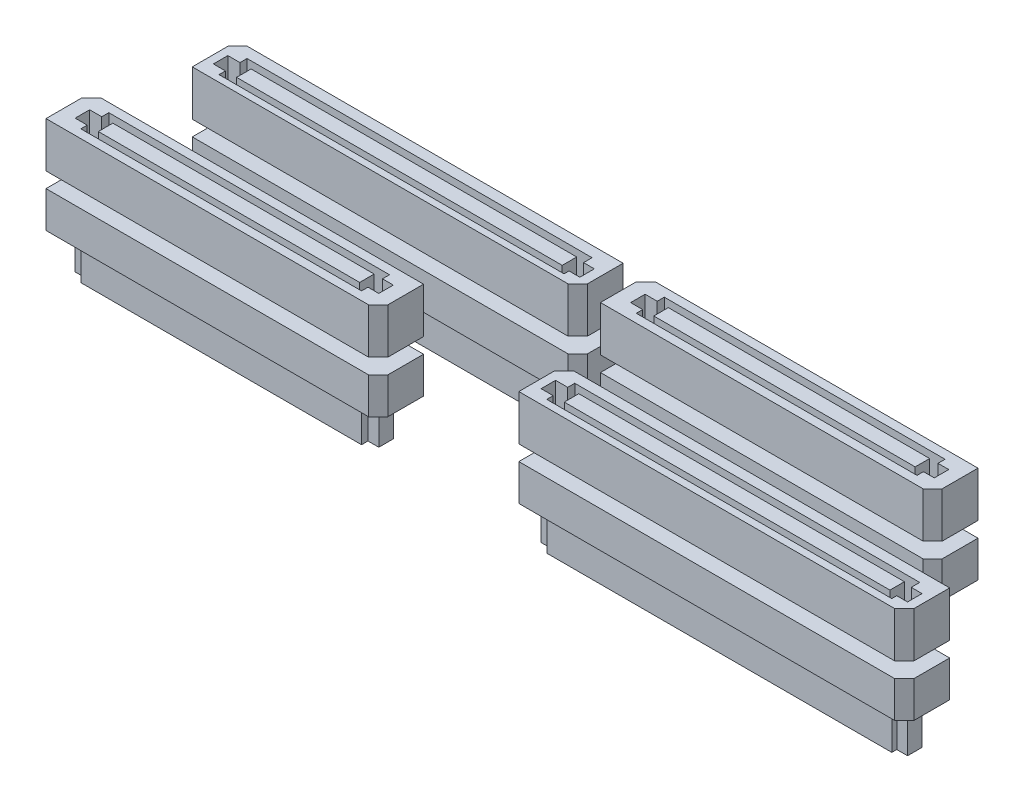
from build123d import *

# Parameters (mm, degrees)
SV_DEPTH           = 5
SV_2_DEPTH         = 5
SV_3_DEPTH         = 5
SV_4_DEPTH         = 5
SKETCH3_W          = 28.811718275
SKETCH3_H          = 1.597828601
SKETCH3_W_2        = 35.897762959
SKETCH3_W_3        = 35.897762958
CUT_EXTRUDE1_DEPTH = 4
SV4_A_DEPTH        = 4
SV4_A_2_DEPTH      = 4
SV4_A_3_DEPTH      = 4
SV4_A_4_DEPTH      = 4
SKETCH7_W          = 35.897762958
SKETCH7_H          = 1.597828601
SV4_B_DEPTH        = 4
SKETCH7_W_2        = 28.811718275
SV4_B_2_DEPTH      = 4
SKETCH7_W_3        = 35.897762959
SV4_B_3_DEPTH      = 4
SV4_B_4_DEPTH      = 4


with BuildPart() as part:
    # Sketch1 → SV (new body)
    with BuildSketch(Plane(origin=(0, 0, 0), x_dir=(1, 0, 0), z_dir=(0, 1, 0))):
        Polygon((55.811, 9.5), (97.25, 9.5), (97.25, 5.56), (96.19, 4.5), (54.75, 4.5), (54.75, 8.439), align=None)
    extrude(amount=SV_DEPTH)


with BuildPart() as body_2:
    # Sketch1 → SV 2 (new body)
    with BuildSketch(Plane(origin=(0, 0, 0), x_dir=(1, 0, 0), z_dir=(0, 1, 0))):
        Polygon((3.686, 9.5), (39.25, 9.5), (39.25, 5.555), (38.195, 4.5), (2.625, 4.5), (2.625, 8.439), align=None)
    extrude(amount=SV_2_DEPTH)


with BuildPart() as body_3:
    # Sketch1 → SV 3 (new body)
    with BuildSketch(Plane(origin=(0, 0, 0), x_dir=(1, 0, 0), z_dir=(0, 1, 0))):
        Polygon((51.811, 22.5), (87.375, 22.5), (87.375, 18.555), (86.32, 17.5), (50.75, 17.5), (50.75, 21.439), align=None)
    extrude(amount=SV_3_DEPTH)


with BuildPart() as body_4:
    # Sketch1 → SV 4 (new body)
    with BuildSketch(Plane(origin=(0, 0, 0), x_dir=(1, 0, 0), z_dir=(0, 1, 0))):
        Polygon((6.811, 22.5), (48.25, 22.5), (48.25, 18.56), (47.19, 17.5), (5.75, 17.5), (5.75, 21.439), align=None)
    extrude(amount=SV_4_DEPTH)


with BuildPart() as cut_extrude1_tool:
    # Sketch3 → Cut-Extrude1 (new body)
    with BuildSketch(Plane(origin=(0, 5, 0), x_dir=(1, 0, 0), z_dir=(0, 1, 0))):
        Polygon((4.189336253, 7.745735487), (5.524337048, 7.745735487), (5.524337048, 8.524173538), (36.475691419, 8.524173538), (36.475691419, 7.745735487), (37.666991912, 7.745735487), (37.666991912, 6.147906886), (36.475691419, 6.147906886), (36.475691419, 5.438560322), (5.524337048, 5.438560322), (5.524337048, 6.147906886), (4.189336253, 6.147906886), align=None)
        with Locations((21.152985591, 6.946821187)):
            Rectangle(SKETCH3_W, SKETCH3_H, mode=Mode.SUBTRACT)
        Polygon((52.421116037, 20.753597434), (53.756116831, 20.753597434), (53.756116831, 21.532035485), (84.707471203, 21.532035485), (84.707471203, 20.753597434), (85.898771695, 20.753597434), (85.898771695, 19.155768833), (84.707471203, 19.155768833), (84.707471203, 18.446422269), (53.756116831, 18.446422269), (53.756116831, 19.155768833), (52.421116037, 19.155768833), align=None)
        with Locations((69.384765375, 19.954683133)):
            Rectangle(SKETCH3_W, SKETCH3_H, mode=Mode.SUBTRACT)
        Polygon((55.705906871, 7.599031898), (57.040907666, 7.599031898), (57.040907666, 8.377469948), (95.07830672, 8.377469948), (95.07830672, 7.437727621), (96.269607213, 7.437727621), (96.269607213, 5.83989902), (95.07830672, 5.83989902), (95.07830672, 5.291856733), (57.040907666, 5.291856733), (57.040907666, 6.001203297), (55.705906871, 6.001203297), align=None)
        with Locations((76.21257855, 6.800117597)):
            Rectangle(SKETCH3_W_2, SKETCH3_H, mode=Mode.SUBTRACT)
        Polygon((6.636601859, 20.53972103), (7.971602653, 20.53972103), (7.971602653, 21.318159081), (46.009001708, 21.318159081), (46.009001708, 20.378416754), (47.2003022, 20.378416754), (47.2003022, 18.780588153), (46.009001708, 18.780588153), (46.009001708, 18.232545866), (7.971602653, 18.232545866), (7.971602653, 18.941892429), (6.636601859, 18.941892429), align=None)
        with Locations((27.143273538, 19.74080673)):
            Rectangle(SKETCH3_W_3, SKETCH3_H, mode=Mode.SUBTRACT)
    extrude(amount=-CUT_EXTRUDE1_DEPTH)


with BuildPart() as part_1:
    add(part.part)

    # Cut-Extrude1: cut by cut_extrude1_tool
    add(cut_extrude1_tool.part, mode=Mode.SUBTRACT)


with BuildPart() as body_2_1:
    add(body_2.part)

    # Cut-Extrude1: cut by cut_extrude1_tool
    add(cut_extrude1_tool.part, mode=Mode.SUBTRACT)


with BuildPart() as body_3_1:
    add(body_3.part)

    # Cut-Extrude1: cut by cut_extrude1_tool
    add(cut_extrude1_tool.part, mode=Mode.SUBTRACT)


with BuildPart() as body_4_1:
    add(body_4.part)

    # Cut-Extrude1: cut by cut_extrude1_tool
    add(cut_extrude1_tool.part, mode=Mode.SUBTRACT)


with BuildPart() as body_5:
    # Sketch6 → SV4(a) (new body)
    with BuildSketch(Plane(origin=(0, -1.68656, 0), x_dir=(1, 0, 0), z_dir=(0, 1, 0))):
        Polygon((2.625, 4.5), (38.195, 4.5), (39.25, 5.555), (39.25, 9.5), (3.685, 9.5), (2.625, 8.44), align=None)
    extrude(amount=-SV4_A_DEPTH)


with BuildPart() as body_6:
    # Sketch6 → SV4_a 2 (new body)
    with BuildSketch(Plane(origin=(0, -1.68656, 0), x_dir=(1, 0, 0), z_dir=(0, 1, 0))):
        Polygon((48.25, 18.56191605), (47.18808395, 17.5), (5.75, 17.5), (5.75, 21.44), (6.81, 22.5), (48.25, 22.5), align=None)
    extrude(amount=-SV4_A_2_DEPTH)


with BuildPart() as body_7:
    # Sketch6 → SV4_a 3 (new body)
    with BuildSketch(Plane(origin=(0, -1.68656, 0), x_dir=(1, 0, 0), z_dir=(0, 1, 0))):
        Polygon((54.75, 4.5), (96.19, 4.5), (97.25, 5.56), (97.25, 9.5), (55.81, 9.5), (54.75, 8.44), align=None)
    extrude(amount=-SV4_A_3_DEPTH)


with BuildPart() as body_8:
    # Sketch6 → SV4_a 4 (new body)
    with BuildSketch(Plane(origin=(0, -1.68656, 0), x_dir=(1, 0, 0), z_dir=(0, 1, 0))):
        Polygon((50.75, 17.5), (86.32, 17.5), (87.375, 18.555), (87.375, 22.5), (51.805, 22.5), (50.75, 21.445), align=None)
    extrude(amount=-SV4_A_4_DEPTH)


with BuildPart() as body_9:
    # Sketch7 → SV4(b) (new body)
    with BuildSketch(Plane.XZ.offset(5.68656)):
        Polygon((7.971602653, -21.318159081), (7.971602653, -20.53972103), (6.636601859, -20.53972103), (6.636601859, -18.941892429), (7.971602653, -18.941892429), (7.971602653, -18.232545866), (46.009001708, -18.232545866), (46.009001708, -18.780588153), (47.2003022, -18.780588153), (47.2003022, -20.378416754), (46.009001708, -20.378416754), (46.009001708, -21.318159081), align=None)
        with Locations((27.143273538, -19.74080673)):
            Rectangle(SKETCH7_W, SKETCH7_H, mode=Mode.SUBTRACT)
    extrude(amount=SV4_B_DEPTH)


with BuildPart() as body_10:
    # Sketch7 → SV4_b 2 (new body)
    with BuildSketch(Plane.XZ.offset(5.68656)):
        Polygon((53.756116831, -21.532035485), (84.707471203, -21.532035485), (84.707471203, -20.753597434), (85.898771695, -20.753597434), (85.898771695, -19.155768833), (84.707471203, -19.155768833), (84.707471203, -18.446422269), (53.756116831, -18.446422269), (53.756116831, -19.155768833), (52.421116037, -19.155768833), (52.421116037, -20.753597434), (53.756116831, -20.753597434), align=None)
        with Locations((69.384765375, -19.954683133)):
            Rectangle(SKETCH7_W_2, SKETCH7_H, mode=Mode.SUBTRACT)
    extrude(amount=SV4_B_2_DEPTH)


with BuildPart() as body_11:
    # Sketch7 → SV4_b 3 (new body)
    with BuildSketch(Plane.XZ.offset(5.68656)):
        Polygon((57.040907666, -8.377469948), (57.040907666, -7.599031898), (55.705906871, -7.599031898), (55.705906871, -6.001203297), (57.040907666, -6.001203297), (57.040907666, -5.291856733), (95.07830672, -5.291856733), (95.07830672, -5.83989902), (96.269607213, -5.83989902), (96.269607213, -7.437727621), (95.07830672, -7.437727621), (95.07830672, -8.377469948), align=None)
        with Locations((76.21257855, -6.800117597)):
            Rectangle(SKETCH7_W_3, SKETCH7_H, mode=Mode.SUBTRACT)
    extrude(amount=SV4_B_3_DEPTH)


with BuildPart() as body_12:
    # Sketch7 → SV4_b 4 (new body)
    with BuildSketch(Plane.XZ.offset(5.68656)):
        Polygon((4.189336253, -6.147906886), (5.524337048, -6.147906886), (5.524337048, -5.438560322), (36.475691419, -5.438560322), (36.475691419, -6.147906886), (37.666991912, -6.147906886), (37.666991912, -7.745735487), (36.475691419, -7.745735487), (36.475691419, -8.524173538), (5.524337048, -8.524173538), (5.524337048, -7.745735487), (4.189336253, -7.745735487), align=None)
        with Locations((21.152985591, -6.946821187)):
            Rectangle(SKETCH7_W_2, SKETCH7_H, mode=Mode.SUBTRACT)
    extrude(amount=SV4_B_4_DEPTH)


solid = Compound([part_1.part, body_2_1.part, body_3_1.part, body_4_1.part, body_5.part, body_6.part, body_7.part, body_8.part, body_9.part, body_10.part, body_11.part, body_12.part])
